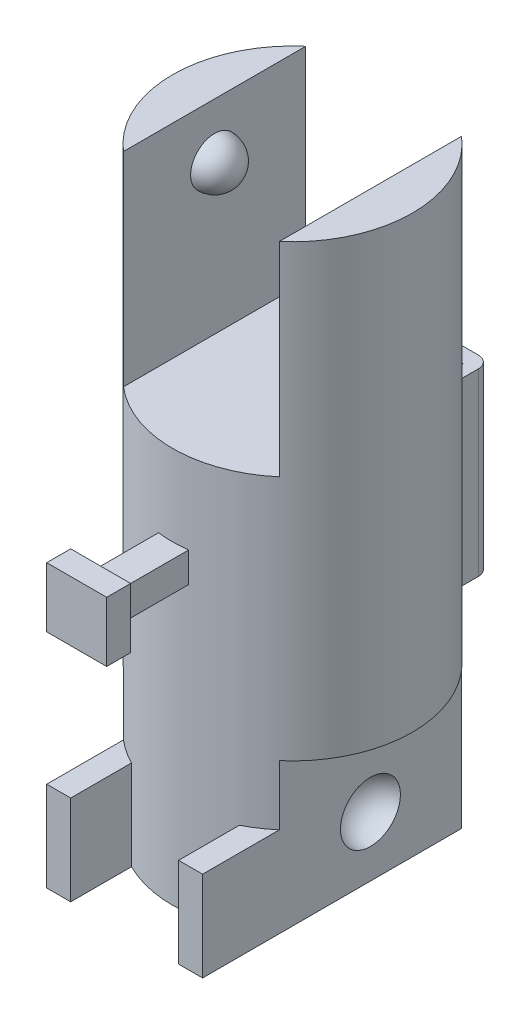
from build123d import *

# Parameters (mm, degrees)
SKETCH3_R            = 10
BOSS_EXTRUDE3_DEPTH  = 50
SKETCH6_W            = 13
SKETCH6_H            = 20
CUT_EXTRUDE4_DEPTH   = 17
SKETCH10_OUTSIDE_W   = 33.49
SKETCH10_OUTSIDE_H   = 33.49
SKETCH10_OUTSIDE_W_2 = 13
SKETCH10_OUTSIDE_H_2 = 20
CUT_EXTRUDE5_DEPTH   = 12.5
BOSS_EXTRUDE4_START  = -0.078433
SKETCH14_W           = 2.5
SKETCH14_H           = 2.5
BOSS_EXTRUDE4_DEPTH  = 6.078433
SKETCH15_W           = 5
SKETCH15_H           = 5
BOSS_EXTRUDE5_DEPTH  = 2
BOSS_EXTRUDE6_START  = -0.317542
SKETCH16_W           = 5
SKETCH16_H           = 15
BOSS_EXTRUDE6_DEPTH  = 4.317542
FILLET2_R            = 1
FILLET3_R            = 1
SKETCH17_W           = 3
SKETCH17_H           = 2.5
CUT_EXTRUDE6_DEPTH   = 29.5
SKETCH18_W           = 6.4
SKETCH18_H           = 7.5
BOSS_EXTRUDE7_DEPTH  = 2


with BuildPart() as part:
    # Sketch3 → Boss-Extrude3 (new body)
    with BuildSketch(Plane(origin=(0, 0, 0), x_dir=(1, 0, 0), z_dir=(0, 1, 0))):
        Circle(SKETCH3_R)
    extrude(amount=-BOSS_EXTRUDE3_DEPTH)

    # Sketch6 → Cut-Extrude4 (cut)
    with BuildSketch(Plane(origin=(0, 0, 0), x_dir=(1, 0, 0), z_dir=(0, 1, 0))):
        Rectangle(SKETCH6_W, SKETCH6_H)
    extrude(amount=-CUT_EXTRUDE4_DEPTH, mode=Mode.SUBTRACT)

    # Sketch7 → Revolve4 (revolve)
    with BuildSketch(Plane(origin=(-6.5, 0, 0), x_dir=(0, 0, -1), z_dir=(1, 0, 0))):
        with BuildLine():
            Line((0.001184262, -2.500000069), (0.001184262, -6.499999723))
            ThreePointArc((0.001184262, -6.499999723), (-1.998815669, -4.5), (0.001184262, -2.500000069))
        make_face()
    revolve4 = revolve(axis=Axis((-6.5, -2.500000069, -0.001184262), (0, -1, 0)))

    # Mirror1: Revolve4 across plane
    add(revolve4.mirror(Plane.ZY))

    # Sketch10 outside → Cut-Extrude5 (cut)
    with BuildSketch(Plane.XZ.offset(50)):
        Rectangle(SKETCH10_OUTSIDE_W, SKETCH10_OUTSIDE_H)
        Rectangle(SKETCH10_OUTSIDE_W_2, SKETCH10_OUTSIDE_H_2, mode=Mode.SUBTRACT)
    extrude(amount=-CUT_EXTRUDE5_DEPTH, mode=Mode.SUBTRACT)

    # Sketch13 → Cut-Revolve1 (revolve, cut)
    with BuildSketch(Plane.ZY.offset(6.5)):
        with BuildLine():
            Line((0, -42.5), (0, -47.5))
            ThreePointArc((0, -47.5), (-2.5, -45), (0, -42.5))
        make_face()
    cut_revolve1 = revolve(axis=Axis((-6.5, -42.5, 0), (0, -1, 0)), mode=Mode.SUBTRACT)

    # Mirror2: Cut-Revolve1 across plane
    add(cut_revolve1.mirror(Plane.ZY), mode=Mode.SUBTRACT)

    # Sketch14 → Boss-Extrude4 (add)
    with BuildSketch(Plane.XY.offset(10).offset(BOSS_EXTRUDE4_START)):
        with Locations((0, -25)):
            Rectangle(SKETCH14_W, SKETCH14_H)
    extrude(amount=BOSS_EXTRUDE4_DEPTH)

    # Sketch15 → Boss-Extrude5 (add)
    with BuildSketch(Plane.XY.offset(16)):
        with Locations((0, -25)):
            Rectangle(SKETCH15_W, SKETCH15_H)
    extrude(amount=BOSS_EXTRUDE5_DEPTH)

    # Sketch16 → Boss-Extrude6 (add)
    with BuildSketch(Plane(origin=(0, 0, -10), x_dir=(-1, 0, 0), z_dir=(0, 0, -1)).offset(BOSS_EXTRUDE6_START)):
        with Locations((0, -29)):
            Rectangle(SKETCH16_W, SKETCH16_H)
    extrude(amount=BOSS_EXTRUDE6_DEPTH)

    # Fillet2
    fillet2_edges = [part.edges().sort_by_distance(p)[0] for p in [
        (2.5, -29, -14),
    ]]
    fillet(fillet2_edges, radius=FILLET2_R)

    # Fillet3
    fillet3_edges = [part.edges().sort_by_distance(p)[0] for p in [
        (-2.5, -29, -14),
    ]]
    fillet(fillet3_edges, radius=FILLET3_R)

    # Sketch17 → Cut-Extrude6 (cut, through all)
    with BuildSketch(Plane(origin=(0, -21.5, 0), x_dir=(1, 0, 0), z_dir=(0, 1, 0))):
        with Locations((0, 11.5)):
            Rectangle(SKETCH17_W, SKETCH17_H)
    extrude(amount=-CUT_EXTRUDE6_DEPTH, mode=Mode.SUBTRACT)

    # Sketch18 → Boss-Extrude7 (add)
    with BuildSketch(Plane.ZY.offset(6.5)):
        with Locations((10.799342077, -46.25)):
            Rectangle(SKETCH18_W, SKETCH18_H)
    boss_extrude7 = extrude(amount=-BOSS_EXTRUDE7_DEPTH)

    # Mirror3: Boss-Extrude7 across plane
    add(boss_extrude7.mirror(Plane(origin=(0, 0, 0), x_dir=(0, 0, 1), z_dir=(1, 0, 0))))


solid = part.part
